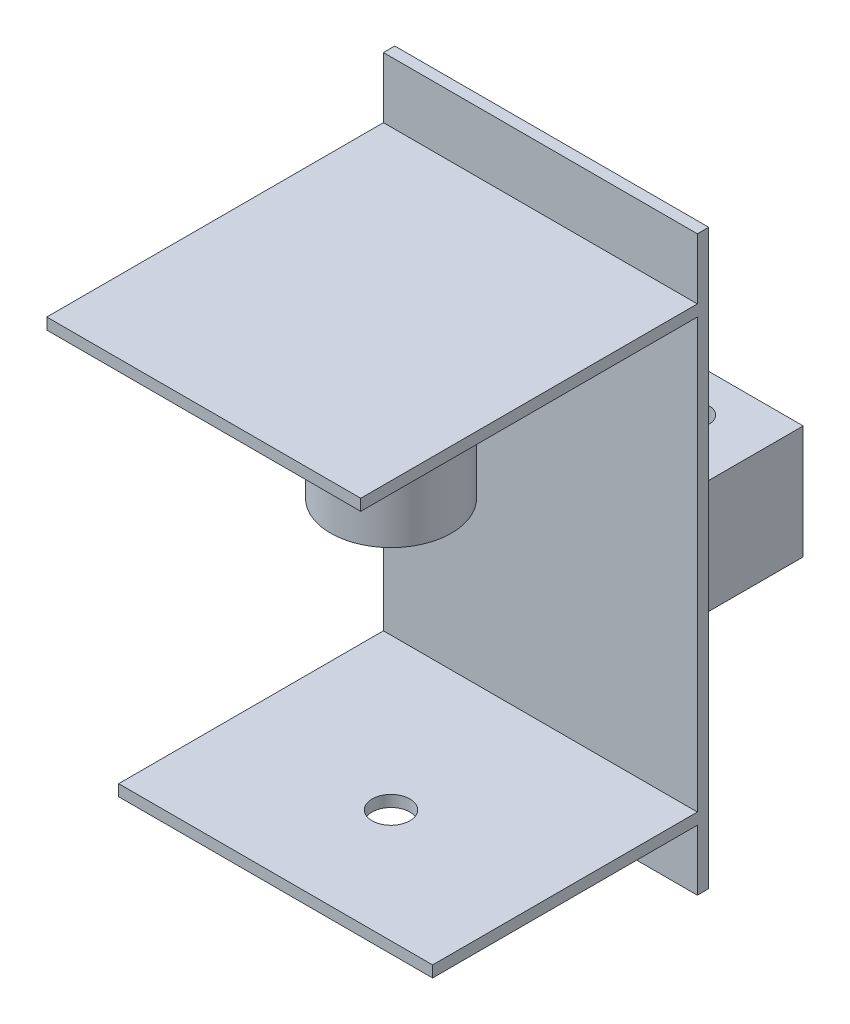
from build123d import *

# Parameters (mm, degrees)
SKETCH1_W           = 83
SKETCH1_H           = 151.45
BOSS_EXTRUDE1_DEPTH = 3
SKETCH2_W           = 83
SKETCH2_H           = 70
BOSS_EXTRUDE2_DEPTH = 3
SKETCH3_W           = 83
SKETCH3_H           = 89
BOSS_EXTRUDE3_DEPTH = 3
SKETCH6_W           = 34
SKETCH6_H           = 28
SKETCH6_R           = 4.15
SKETCH6_H_2         = 30
BOSS_EXTRUDE6_DEPTH = 30
SKETCH7_R           = 16
SKETCH7_R_2         = 15
BOSS_EXTRUDE7_DEPTH = 42
SKETCH8_R           = 5
CUT_EXTRUDE1_DEPTH  = 20.05


with BuildPart() as part:
    # Sketch1 → Boss-Extrude1 (new body)
    with BuildSketch(Plane.XY):
        with Locations((41.5, 75.725)):
            Rectangle(SKETCH1_W, SKETCH1_H)
    extrude(amount=BOSS_EXTRUDE1_DEPTH)

    # Sketch2 → Boss-Extrude2 (add)
    with BuildSketch(Plane(origin=(0, 16.05, 0), x_dir=(-1, 0, 0), z_dir=(0, -1, 0))):
        with Locations((-41.5, -38)):
            Rectangle(SKETCH2_W, SKETCH2_H)
    boss_extrude2 = extrude(amount=-BOSS_EXTRUDE2_DEPTH)

    # Mirror1: Boss-Extrude2 across plane
    add(boss_extrude2.mirror(Plane.ZX.offset(75.725)))

    # Sketch3 → Boss-Extrude3 (add)
    with BuildSketch(Plane(origin=(0, 135.4, 0), x_dir=(1, 0, 0), z_dir=(0, 1, 0))):
        with Locations((41.5, -47.5)):
            Rectangle(SKETCH3_W, SKETCH3_H)
    extrude(amount=-BOSS_EXTRUDE3_DEPTH)

    # Sketch6 → Boss-Extrude6 (add)
    with BuildSketch(Plane(origin=(0, 88.45, 0), x_dir=(1, 0, 0), z_dir=(0, 1, 0))):
        with Locations((21.979, 14)):
            Rectangle(SKETCH6_W, SKETCH6_H)
        with Locations((21.979, 18)):
            Circle(SKETCH6_R, mode=Mode.SUBTRACT)
        with Locations((60.98, 15)):
            Rectangle(SKETCH6_W, SKETCH6_H_2)
        with Locations((60.98, 18)):
            Circle(SKETCH6_R, mode=Mode.SUBTRACT)
    extrude(amount=-BOSS_EXTRUDE6_DEPTH)

    # Sketch7 → Boss-Extrude7 (add)
    with BuildSketch(Plane.XZ.offset(-132.4)):
        with Locations((42, 43)):
            Circle(SKETCH7_R)
        with Locations((42, 43)):
            Circle(SKETCH7_R_2, mode=Mode.SUBTRACT)
    extrude(amount=BOSS_EXTRUDE7_DEPTH)

    # Sketch8 → Cut-Extrude1 (cut, through all)
    with BuildSketch(Plane(origin=(0, 19.05, 0), x_dir=(1, 0, 0), z_dir=(0, 1, 0))):
        with Locations((42, -43)):
            Circle(SKETCH8_R)
    extrude(amount=-CUT_EXTRUDE1_DEPTH, mode=Mode.SUBTRACT)


solid = part.part
